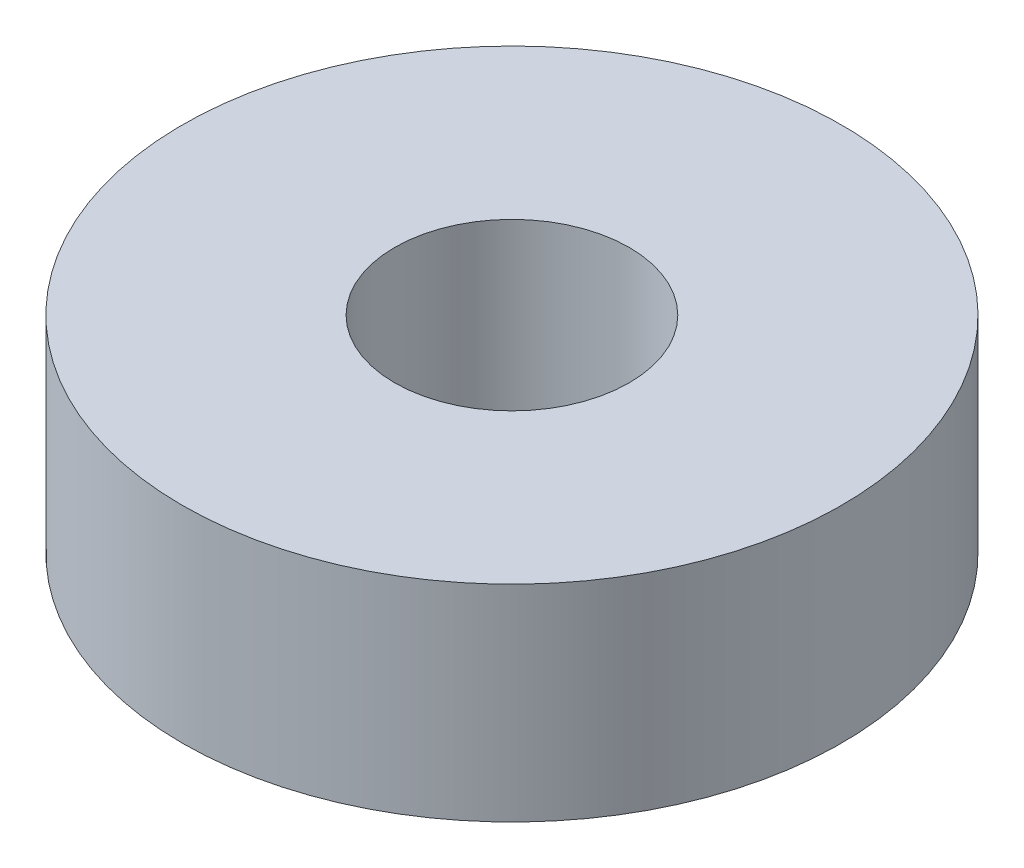
from build123d import *

# Parameters (mm, degrees)
SKETCH_1_R          = 16
EXTRUDE_1_DEPTH     = 10
SKETCH_2_R          = 5.69460229
CUT_EXTRUDE_1_DEPTH = 11


with BuildPart() as part:
    # 草圖1 → 填料-伸長1 (new body)
    with BuildSketch(Plane(origin=(0, 0, 0), x_dir=(1, 0, 0), z_dir=(0, 1, 0))):
        Circle(SKETCH_1_R)
    extrude(amount=EXTRUDE_1_DEPTH)

    # 草圖2 → 除料-伸長1 (cut, through all)
    with BuildSketch(Plane(origin=(0, 10, 0), x_dir=(1, 0, 0), z_dir=(0, 1, 0))):
        Circle(SKETCH_2_R)
    extrude(amount=-CUT_EXTRUDE_1_DEPTH, mode=Mode.SUBTRACT)


solid = part.part
